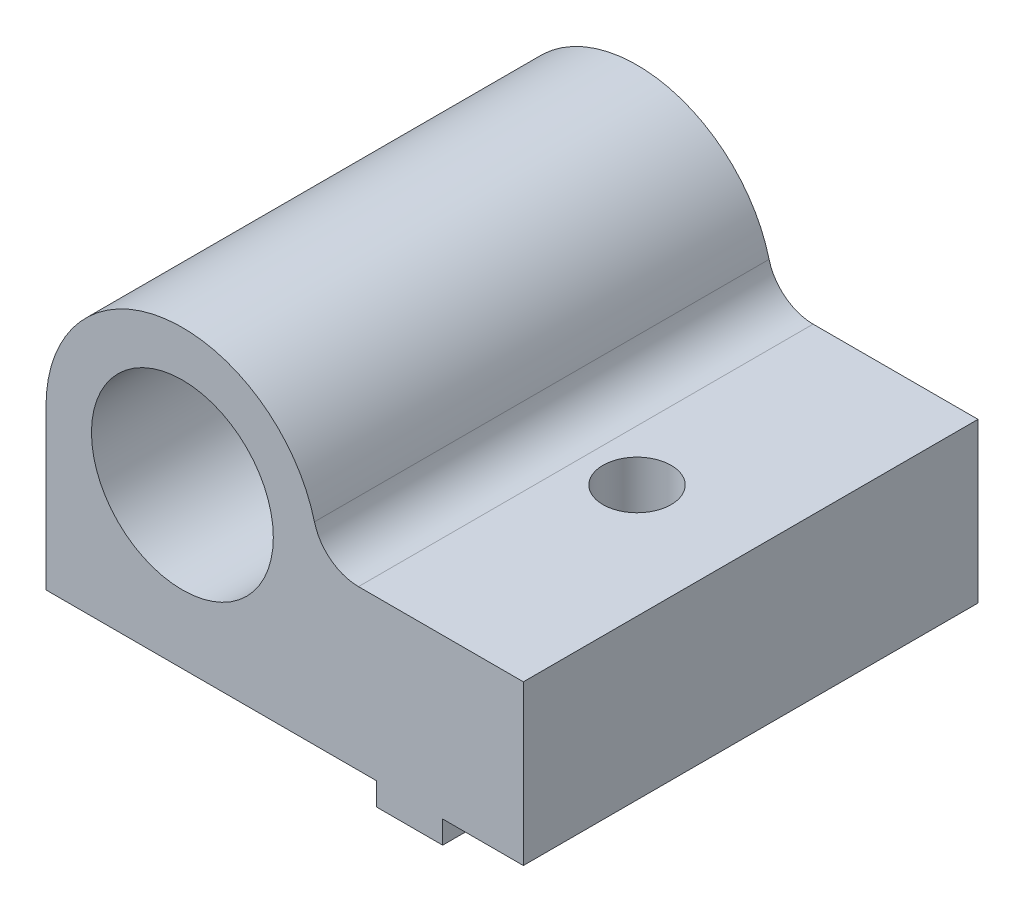
from build123d import *

# Parameters (mm, degrees)
SKETCH1_R                       = 4
MAIN_DEPTH                      = 10
SKETCH3_W                       = 2.9
SKETCH3_H                       = 20
MAKERBEAMRECTANGULARGUIDE_DEPTH = 1
SKETCH4_R                       = 1.5
MAKERBEAMFIXHOLE_DEPTH          = 9
FILLET1_R                       = 2


with BuildPart() as part:
    # Sketch1 → Main (new body, symmetric)
    with BuildSketch(Plane.XY):
        with BuildLine():
            Line((-6, 0), (-6, -7))
            Line((-6, -7), (15, -7))
            Line((15, -7), (15, 0))
            Line((15, 0), (6, 0))
            ThreePointArc((6, 0), (0, 6), (-6, 0))
        make_face()
        Circle(SKETCH1_R, mode=Mode.SUBTRACT)
    extrude(amount=MAIN_DEPTH, both=True)

    # Sketch3 → MakerBeamRectangularGuide (add)
    with BuildSketch(Plane(origin=(0, -7, 0), x_dir=(-1, 0, 0), z_dir=(0, -1, 0))):
        with Locations((-10, 0)):
            Rectangle(SKETCH3_W, SKETCH3_H)
    extrude(amount=MAKERBEAMRECTANGULARGUIDE_DEPTH)

    # Sketch4 → MakerBeamFixHole (cut, through all)
    with BuildSketch(Plane(origin=(0, 0, 0), x_dir=(1, 0, 0), z_dir=(0, 1, 0))):
        with Locations((10, 0)):
            Circle(SKETCH4_R)
    extrude(amount=-MAKERBEAMFIXHOLE_DEPTH, mode=Mode.SUBTRACT)

    # Fillet1
    fillet1_edges = [part.edges().sort_by_distance(p)[0] for p in [
        (6, 0, 0),
    ]]
    fillet(fillet1_edges, radius=FILLET1_R)


solid = part.part
